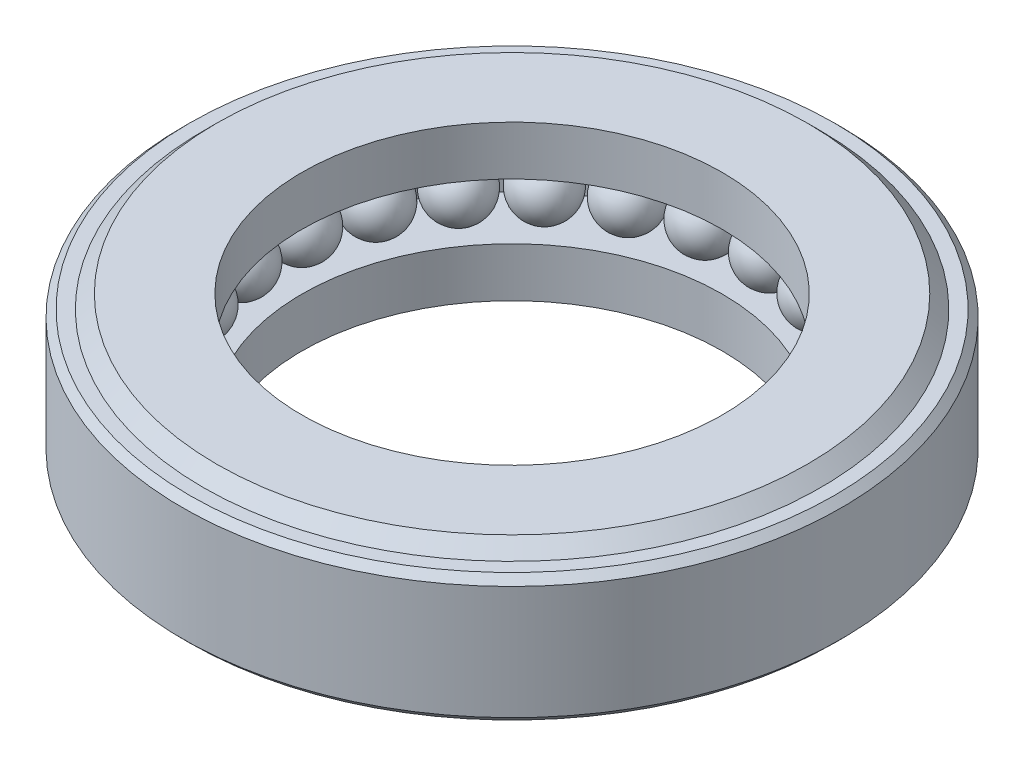
from build123d import *

# Parameters (mm, degrees)
CIRPATTERN1_COUNT = 25


with BuildPart() as part:
    # Sketch2 → Revolve1 (revolve)
    with BuildSketch(Plane.XY):
        Polygon((2.94, 0.5067), (2.94, -0.5067), (2.8767, -0.57), (2.755, -0.57), (2.635, -0.69), (1.875, -0.69), (1.875, -0.25), (2.44, -0.25), (2.44, 0.25), (1.875, 0.25), (1.875, 0.69), (2.635, 0.69), (2.755, 0.57), (2.8767, 0.57), align=None)
    revolve(axis=Axis((0, 0, 0), (0, 1, 0)))

    # Sketch3 → Revolve2 (revolve)
    with BuildSketch(Plane.XY):
        with BuildLine():
            Line((2.165, 0.26), (2.165, -0.26))
            ThreePointArc((2.165, -0.26), (2.425, 0), (2.165, 0.26))
        make_face()
    revolve2 = revolve(axis=Axis((2.165, 0.26, 0), (0, -1, 0)))

    # CirPattern1: Revolve2 ×25 about axis
    cirpattern1_axis = Axis((0, 0, 0), (0, 1, 0))
    for i in range(1, CIRPATTERN1_COUNT):
        add(revolve2.rotate(cirpattern1_axis, i * 360 / CIRPATTERN1_COUNT))


solid = part.part
